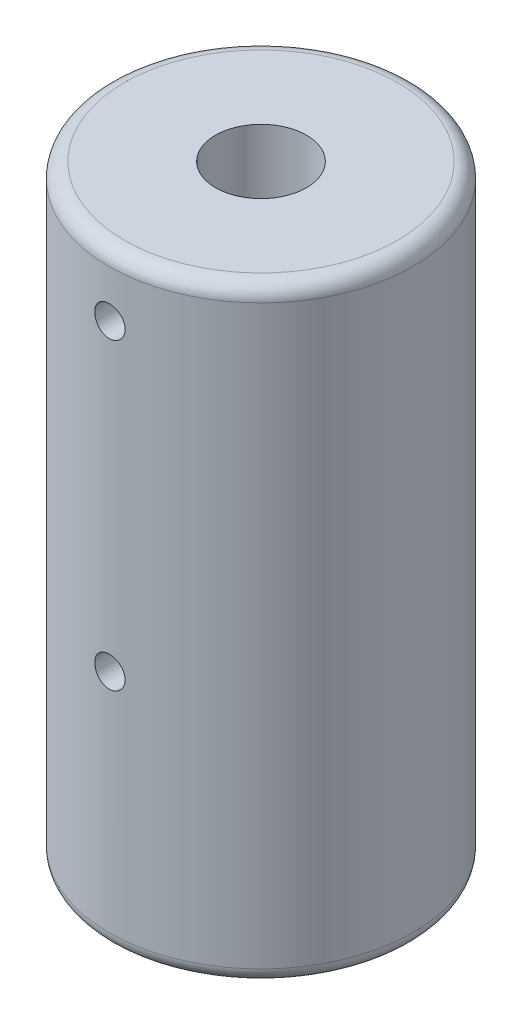
from build123d import *

# Parameters (mm, degrees)
SKETCH1_R           = 10
BOSS_EXTRUDE1_DEPTH = 40
FILLET1_R           = 1
FILLET2_R           = 1
SKETCH2_R           = 3
CUT_EXTRUDE1_DEPTH  = 41
CUT_EXTRUDE2_REACH  = 22
SKETCH4_R           = 1


with BuildPart() as part:
    # Sketch1 → Boss-Extrude1 (new body)
    with BuildSketch(Plane(origin=(0, 0, 0), x_dir=(1, 0, 0), z_dir=(0, 1, 0))):
        Circle(SKETCH1_R)
    extrude(amount=BOSS_EXTRUDE1_DEPTH)

    # Fillet1
    fillet1_edges = [part.edges().sort_by_distance(p)[0] for p in [
        (-10, 40, 0),
    ]]
    fillet(fillet1_edges, radius=FILLET1_R)

    # Fillet2
    fillet2_edges = [part.edges().sort_by_distance(p)[0] for p in [
        (-10, 0, 0),
    ]]
    fillet(fillet2_edges, radius=FILLET2_R)

    # Sketch2 → Cut-Extrude1 (cut, through all)
    with BuildSketch(Plane(origin=(0, 40, 0), x_dir=(1, 0, 0), z_dir=(0, 1, 0))):
        Circle(SKETCH2_R)
    extrude(amount=-CUT_EXTRUDE1_DEPTH, mode=Mode.SUBTRACT)

    # Sketch4 → Cut-Extrude2 (cut, up to next)
    with BuildSketch(Plane(origin=(0, 40, 10), x_dir=(1, 0, 0), z_dir=(0, 0, 1)), mode=Mode.PRIVATE) as cut_extrude2_sk1:
        with Locations((0, -4.106598233)):
            Circle(SKETCH4_R)
    cut_extrude2_tool1 = extrude(cut_extrude2_sk1.sketch, amount=-CUT_EXTRUDE2_REACH, mode=Mode.PRIVATE) & part.part
    add(cut_extrude2_tool1.solids().sort_by_distance((0, 35.893402, 10))[0], mode=Mode.SUBTRACT)
    # Sketch4 → Cut-Extrude2 (cut, up to next)
    with BuildSketch(Plane(origin=(0, 40, 10), x_dir=(1, 0, 0), z_dir=(0, 0, 1)), mode=Mode.PRIVATE) as cut_extrude2_sk2:
        with Locations((0, -24.106598233)):
            Circle(SKETCH4_R)
    cut_extrude2_tool2 = extrude(cut_extrude2_sk2.sketch, amount=-CUT_EXTRUDE2_REACH, mode=Mode.PRIVATE) & part.part
    add(cut_extrude2_tool2.solids().sort_by_distance((0, 15.893402, 10))[0], mode=Mode.SUBTRACT)


solid = part.part
